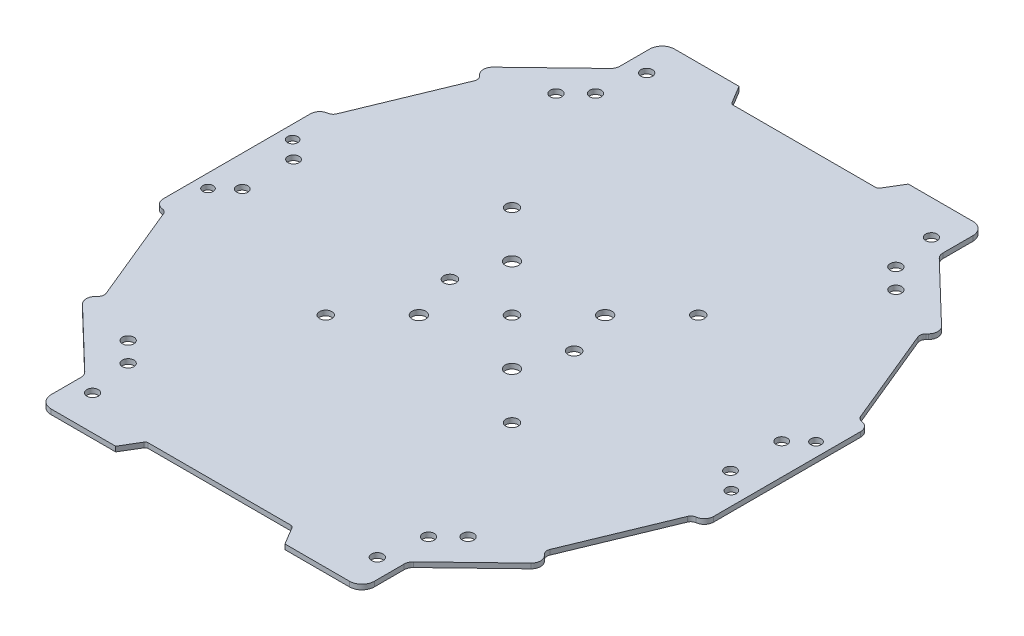
from build123d import *

# Parameters (mm, degrees)
SKETCH1_R        = 2.2
SKETCH1_R_2      = 1.85915493
SKETCH1_R_3      = 2
SKETCH1_R_4      = 1.8
SKETCH1_R_5      = 1.673239437
SKETCH1_R_6      = 1.983111479
EXTRUSION1_DEPTH = 1.6
FILLET1_R        = 1
FILLET2_R        = 4
FILLET3_R        = 3
FILLET4_R        = 3
FILLET5_R        = 2
FILLET6_R        = 2
FILLET7_R        = 3
FILLET8_R        = 3
FILLET9_R        = 2
FILLET10_R       = 2
FILLET11_R       = 3


with BuildPart() as part:
    # Sketch1 → Extrusion1 (new body)
    with BuildSketch(Plane(origin=(0, 0, 0), x_dir=(-1, 0, 0), z_dir=(0, 1, 0))):
        Polygon((74.087520418, 321.088295015), (70.369210559, 327.285477572), (45.580478165, 327.285477572), (45.580478165, 312.412238135), (23.246043749, 290.934342561), (26.682507041, 287.360833055), (12.735407819, 253.538985229), (9.017097883, 253.538985229), (9.017097883, 226.891111382), (9.017097883, 200.243237534), (12.735407819, 200.243237534), (26.682507041, 166.421389708), (23.246043749, 162.847880202), (45.580478165, 141.369984628), (45.580478165, 126.496745191), (70.369210559, 126.496745191), (74.087520418, 132.693927748), (97.636816193, 132.693927748), (121.186111968, 132.693927748), (124.904421827, 126.496745191), (149.693154221, 126.496745191), (149.693154221, 141.369984628), (172.027588636, 162.847880202), (168.591125345, 166.421389708), (182.538224567, 200.243237534), (186.256534503, 200.243237534), (186.256534503, 226.891111382), (186.256534503, 253.538985229), (182.538224567, 253.538985229), (168.591125345, 287.360833055), (172.027588636, 290.934342561), (149.693154221, 312.412238135), (149.693154221, 327.285477572), (124.904421827, 327.285477572), (121.186111968, 321.088295015), (97.636816193, 321.088295015), align=None)
        with Locations((112.636816193, 211.891111382)):
            Circle(SKETCH1_R, mode=Mode.SUBTRACT)
        with Locations((49.266182018, 151.62213525)):
            Circle(SKETCH1_R_2, mode=Mode.SUBTRACT)
        with Locations((112.636816193, 241.891111382)):
            Circle(SKETCH1_R, mode=Mode.SUBTRACT)
        with Locations((82.636816193, 241.891111382)):
            Circle(SKETCH1_R, mode=Mode.SUBTRACT)
        with Locations((82.636816193, 211.891111382)):
            Circle(SKETCH1_R, mode=Mode.SUBTRACT)
        with Locations((117.636816193, 226.891111382)):
            Circle(SKETCH1_R_3, mode=Mode.SUBTRACT)
        with Locations((77.636816193, 226.891111382)):
            Circle(SKETCH1_R_3, mode=Mode.SUBTRACT)
        with Locations((97.636816193, 226.891111382)):
            Circle(SKETCH1_R_3, mode=Mode.SUBTRACT)
        with Locations((176.256534503, 218.641111382)):
            Circle(SKETCH1_R_4, mode=Mode.SUBTRACT)
        with Locations((176.256534503, 235.141111382)):
            Circle(SKETCH1_R_4, mode=Mode.SUBTRACT)
        with Locations((19.017097883, 218.641111382)):
            Circle(SKETCH1_R_4, mode=Mode.SUBTRACT)
        with Locations((19.017097883, 235.141111382)):
            Circle(SKETCH1_R_4, mode=Mode.SUBTRACT)
        with Locations((51.777661187, 316.130534525)):
            Circle(SKETCH1_R_2, mode=Mode.SUBTRACT)
        with Locations((49.266182018, 302.160087513)):
            Circle(SKETCH1_R_2, mode=Mode.SUBTRACT)
        with Locations((13.355125975, 240.524915841)):
            Circle(SKETCH1_R_5, mode=Mode.SUBTRACT)
        with Locations((143.495971199, 137.651688238)):
            Circle(SKETCH1_R_2, mode=Mode.SUBTRACT)
        with Locations((146.007450368, 151.62213525)):
            Circle(SKETCH1_R_2, mode=Mode.SUBTRACT)
        with Locations((143.495971199, 316.130534525)):
            Circle(SKETCH1_R_2, mode=Mode.SUBTRACT)
        with Locations((181.918506411, 240.524915841)):
            Circle(SKETCH1_R_5, mode=Mode.SUBTRACT)
        with Locations((146.007450368, 302.160087513)):
            Circle(SKETCH1_R_2, mode=Mode.SUBTRACT)
        with Locations((181.918506411, 213.257306923)):
            Circle(SKETCH1_R_5, mode=Mode.SUBTRACT)
        with Locations((13.355125975, 213.257306923)):
            Circle(SKETCH1_R_5, mode=Mode.SUBTRACT)
        with Locations((51.777661187, 137.651688238)):
            Circle(SKETCH1_R_2, mode=Mode.SUBTRACT)
        with Locations((67.636816193, 196.891111382)):
            Circle(SKETCH1_R_6, mode=Mode.SUBTRACT)
        with Locations((67.636816193, 256.891111382)):
            Circle(SKETCH1_R_6, mode=Mode.SUBTRACT)
        with Locations((42.888078851, 158.000238416)):
            Circle(SKETCH1_R_2, mode=Mode.SUBTRACT)
        with Locations((152.385553534, 295.781984347)):
            Circle(SKETCH1_R_2, mode=Mode.SUBTRACT)
        with Locations((42.888078851, 295.781984347)):
            Circle(SKETCH1_R_2, mode=Mode.SUBTRACT)
        with Locations((127.636816193, 256.891111382)):
            Circle(SKETCH1_R_6, mode=Mode.SUBTRACT)
        with Locations((152.385553534, 158.000238416)):
            Circle(SKETCH1_R_2, mode=Mode.SUBTRACT)
        with Locations((127.636816193, 196.891111382)):
            Circle(SKETCH1_R_6, mode=Mode.SUBTRACT)
    extrude(amount=EXTRUSION1_DEPTH)

    # Fillet1
    fillet1_edges = [part.edges().sort_by_distance(p)[0] for p in [
        (-121.186111968, 0.8, 321.088295015),
        (-121.186111968, 0.8, 132.693927748),
        (-74.087520418, 0.8, 132.693927748),
        (-74.087520418, 0.8, 321.088295015),
    ]]
    fillet(fillet1_edges, radius=FILLET1_R)

    # Fillet2
    fillet2_edges = [part.edges().sort_by_distance(p)[0] for p in [
        (-149.693154221, 0.8, 327.285477572),
        (-149.693154221, 0.8, 126.496745191),
        (-45.580478165, 0.8, 126.496745191),
        (-45.580478165, 0.8, 327.285477572),
    ]]
    fillet(fillet2_edges, radius=FILLET2_R)

    # Fillet3
    fillet3_edges = [part.edges().sort_by_distance(p)[0] for p in [
        (-149.693154221, 0.8, 312.412238135),
        (-149.693154221, 0.8, 141.369984628),
        (-45.580478165, 0.8, 141.369984628),
        (-45.580478165, 0.8, 312.412238135),
    ]]
    fillet(fillet3_edges, radius=FILLET3_R)

    # Fillet4
    fillet4_edges = [part.edges().sort_by_distance(p)[0] for p in [
        (-172.027588636, 0.8, 290.934342561),
    ]]
    fillet(fillet4_edges, radius=FILLET4_R)

    # Fillet5
    fillet5_edges = [part.edges().sort_by_distance(p)[0] for p in [
        (-168.591125345, 0.8, 287.360833055),
    ]]
    fillet(fillet5_edges, radius=FILLET5_R)

    # Fillet6
    fillet6_edges = [part.edges().sort_by_distance(p)[0] for p in [
        (-26.682507041, 0.8, 287.360833055),
    ]]
    fillet(fillet6_edges, radius=FILLET6_R)

    # Fillet7
    fillet7_edges = [part.edges().sort_by_distance(p)[0] for p in [
        (-23.246043749, 0.8, 290.934342561),
    ]]
    fillet(fillet7_edges, radius=FILLET7_R)

    # Fillet8
    fillet8_edges = [part.edges().sort_by_distance(p)[0] for p in [
        (-172.027588636, 0.8, 162.847880202),
        (-23.246043749, 0.8, 162.847880202),
    ]]
    fillet(fillet8_edges, radius=FILLET8_R)

    # Fillet9
    fillet9_edges = [part.edges().sort_by_distance(p)[0] for p in [
        (-168.591125345, 0.8, 166.421389708),
        (-26.682507041, 0.8, 166.421389708),
    ]]
    fillet(fillet9_edges, radius=FILLET9_R)

    # Fillet10
    fillet10_edges = [part.edges().sort_by_distance(p)[0] for p in [
        (-182.538224567, 0.8, 253.538985229),
        (-182.538224567, 0.8, 200.243237534),
        (-12.735407819, 0.8, 200.243237534),
        (-12.735407819, 0.8, 253.538985229),
    ]]
    fillet(fillet10_edges, radius=FILLET10_R)

    # Fillet11
    fillet11_edges = [part.edges().sort_by_distance(p)[0] for p in [
        (-186.256534503, 0.8, 200.243237534),
        (-186.256534503, 0.8, 253.538985229),
        (-9.017097883, 0.8, 253.538985229),
        (-9.017097883, 0.8, 200.243237534),
    ]]
    fillet(fillet11_edges, radius=FILLET11_R)


solid = part.part
